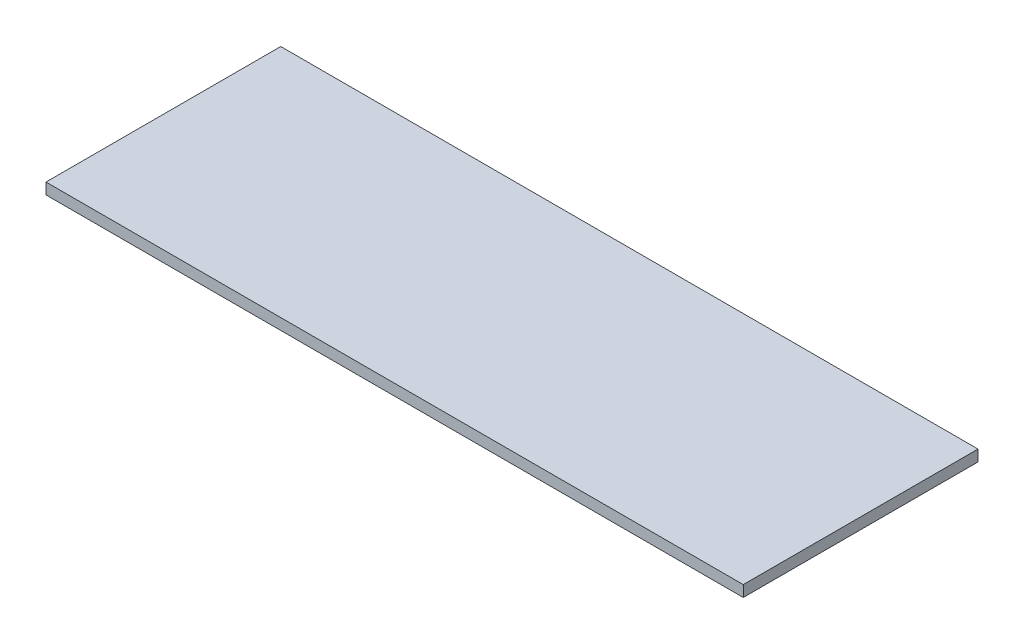
from build123d import *

# Parameters (mm, degrees)
SKETCH1_W           = 1188.1
SKETCH1_H           = 400
BOSS_EXTRUDE1_DEPTH = 19.05


with BuildPart() as part:
    # Sketch1 → Boss-Extrude1 (new body)
    with BuildSketch(Plane(origin=(0, 0, 0), x_dir=(1, 0, 0), z_dir=(0, 1, 0))):
        with Locations((594.05, 200)):
            Rectangle(SKETCH1_W, SKETCH1_H)
    extrude(amount=BOSS_EXTRUDE1_DEPTH)


solid = part.part
